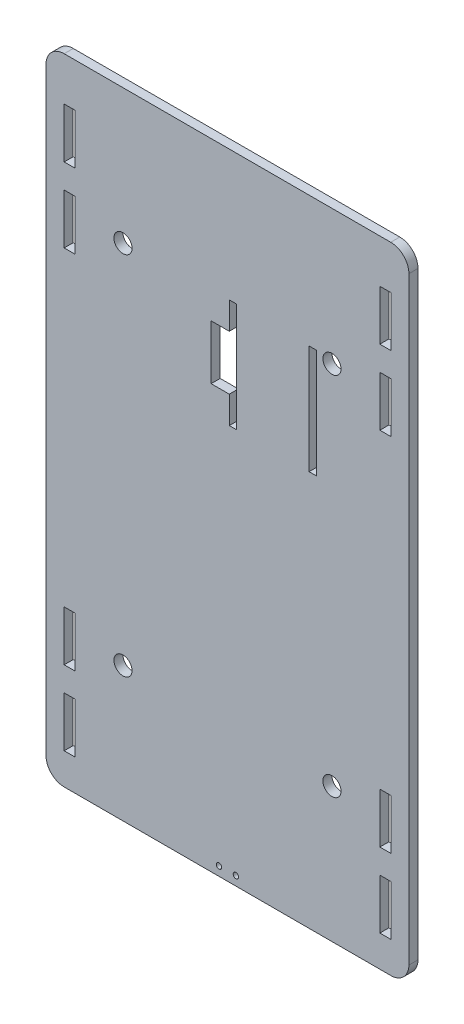
from build123d import *

# Parameters (mm, degrees)
SKETCH1_R           = 5
BOSS_EXTRUDE1_DEPTH = 5
SKETCH4_W           = 4
SKETCH4_H           = 60
CUT_EXTRUDE1_DEPTH  = 10
SKETCH5_R           = 1.5
SKETCH5_W           = 6
SKETCH5_H           = 27.65
CUT_EXTRUDE2_DEPTH  = 6
FILLET1_R           = 10


with BuildPart() as part:
    # Sketch1 → Boss-Extrude1 (new body)
    with BuildSketch(Plane.XY):
        Polygon((100, 190), (-100, 190), (-100, -90), (-100, -160), (100, -160), (100, -90), align=None)
        with Locations((-57.587555345, 115.778221854)):
            Circle(SKETCH1_R, mode=Mode.SUBTRACT)
        with Locations((57.587555345, 115.778221854)):
            Circle(SKETCH1_R, mode=Mode.SUBTRACT)
        with Locations((57.587555345, -85.778221854)):
            Circle(SKETCH1_R, mode=Mode.SUBTRACT)
        with Locations((-57.587555345, -85.778221854)):
            Circle(SKETCH1_R, mode=Mode.SUBTRACT)
    extrude(amount=BOSS_EXTRUDE1_DEPTH)

    # Sketch4 → Cut-Extrude1 (cut)
    with BuildSketch(Plane.XY.offset(5)):
        Polygon((1, 73), (1, 58), (5, 58), (5, 118), (1, 118), (1, 103), (-9, 103), (-9, 73), align=None)
        with Locations((47, 88)):
            Rectangle(SKETCH4_W, SKETCH4_H)
    extrude(amount=-CUT_EXTRUDE1_DEPTH, mode=Mode.SUBTRACT)

    # Sketch5 → Cut-Extrude2 (cut, through all)
    with BuildSketch(Plane.XY.offset(5)):
        with Locations((4.67, -155)):
            Circle(SKETCH5_R)
        with Locations((-4.67, -155)):
            Circle(SKETCH5_R)
        with Locations((-87, 152.175)):
            Rectangle(SKETCH5_W, SKETCH5_H)
        with Locations((-87, 111.115)):
            Rectangle(SKETCH5_W, SKETCH5_H)
        with Locations((-87, -87.845)):
            Rectangle(SKETCH5_W, SKETCH5_H)
        with Locations((-87, -128.905)):
            Rectangle(SKETCH5_W, SKETCH5_H)
        with Locations((87, -87.845)):
            Rectangle(SKETCH5_W, SKETCH5_H)
        with Locations((87, -128.905)):
            Rectangle(SKETCH5_W, SKETCH5_H)
        with Locations((87, 152.175)):
            Rectangle(SKETCH5_W, SKETCH5_H)
        with Locations((87, 111.115)):
            Rectangle(SKETCH5_W, SKETCH5_H)
    extrude(amount=-CUT_EXTRUDE2_DEPTH, mode=Mode.SUBTRACT)

    # Fillet1
    fillet1_edges = [part.edges().sort_by_distance(p)[0] for p in [
        (-100, 190, 2.5),
        (100, 190, 2.5),
        (100, -160, 2.5),
        (-100, -160, 2.5),
    ]]
    fillet(fillet1_edges, radius=FILLET1_R)


solid = part.part
